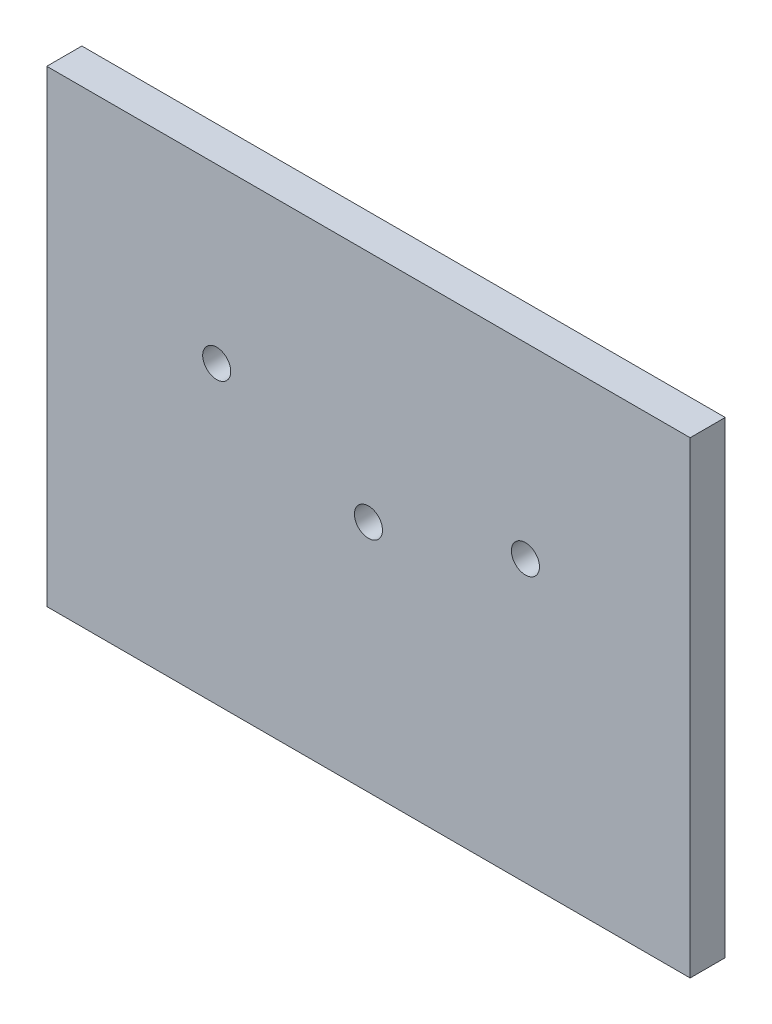
from build123d import *

# Parameters (mm, degrees)
ESBO_O1_W                = 550
ESBO_O1_H                = 400
ESBO_O1_R                = 12
RESSALTO_EXTRUS_O1_DEPTH = 30


with BuildPart() as part:
    # Esboço1 → Ressalto-extrusão1 (new body)
    with BuildSketch(Plane.XY):
        Rectangle(ESBO_O1_W, ESBO_O1_H)
        with Locations((-129.722465626, 52.650564213)):
            Circle(ESBO_O1_R, mode=Mode.SUBTRACT)
        Circle(ESBO_O1_R, mode=Mode.SUBTRACT)
        with Locations((134.18182058, 39.940443486)):
            Circle(ESBO_O1_R, mode=Mode.SUBTRACT)
    extrude(amount=RESSALTO_EXTRUS_O1_DEPTH)


solid = part.part
